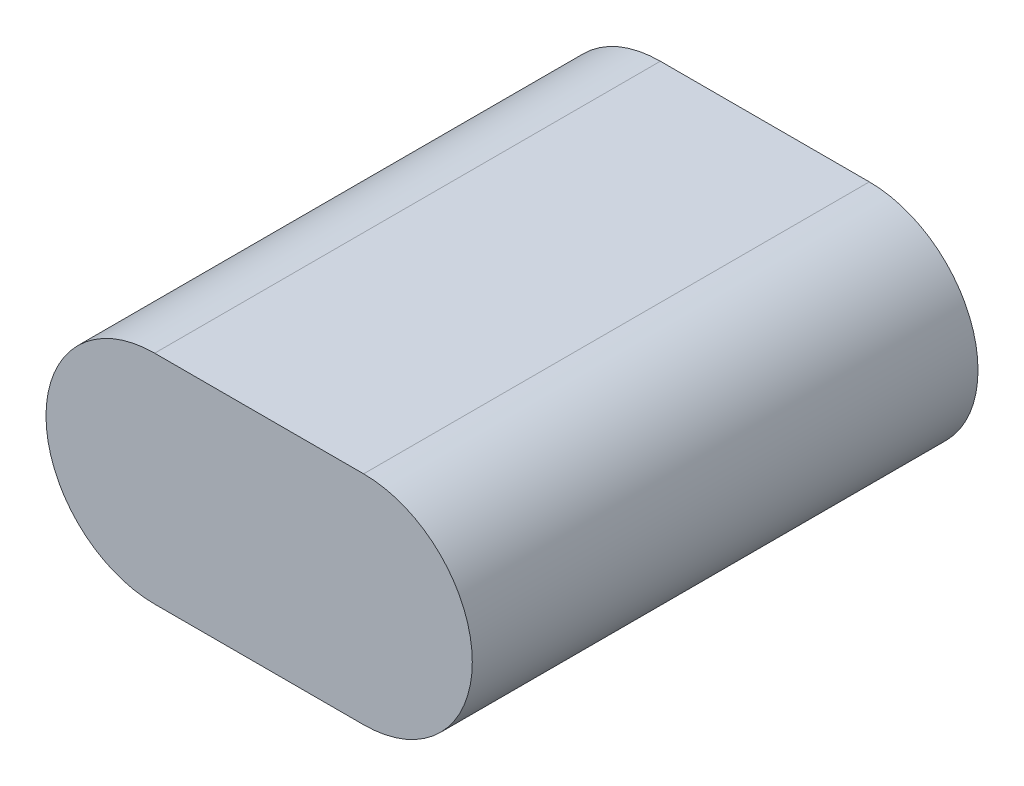
from build123d import *

# Parameters (mm, degrees)
EXTRUDE_1_DEPTH = 242


with BuildPart() as part:
    # 草图1 → 凸台-拉伸1 (new body)
    with BuildSketch(Plane.XY):
        with BuildLine():
            Line((-50, 52), (50, 52))
            ThreePointArc((50, 52), (102, 0), (50, -52))
            Line((50, -52), (-50, -52))
            ThreePointArc((-50, -52), (-102, 0), (-50, 52))
        make_face()
    extrude(amount=EXTRUDE_1_DEPTH)


solid = part.part
